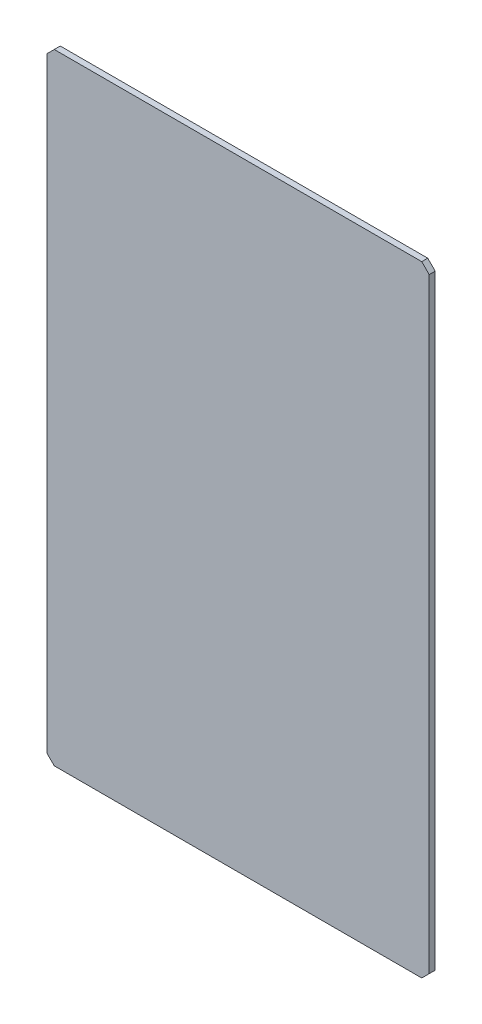
from build123d import *

# Parameters (mm, degrees)
SKETCH_1_W      = 76.5
SKETCH_1_H      = 124.087488664
EXTRUDE_1_DEPTH = 1.2
CHAMFER_1_SIZE  = 1.5


with BuildPart() as part:
    # 草图1 → 凸台-拉伸1 (new body)
    with BuildSketch(Plane.XY):
        with Locations((9.950404768, 36.629314437)):
            Rectangle(SKETCH_1_W, SKETCH_1_H)
    extrude(amount=EXTRUDE_1_DEPTH)

    # 倒角1
    chamfer_1_edges = [part.edges().sort_by_distance(p)[0] for p in [
        (48.200404768, -25.414429895, 0.6),
        (-28.299595232, -25.414429895, 0.6),
        (-28.299595232, 98.673058769, 0.6),
        (48.200404768, 98.673058769, 0.6),
    ]]
    chamfer(chamfer_1_edges, length=CHAMFER_1_SIZE)


solid = part.part
